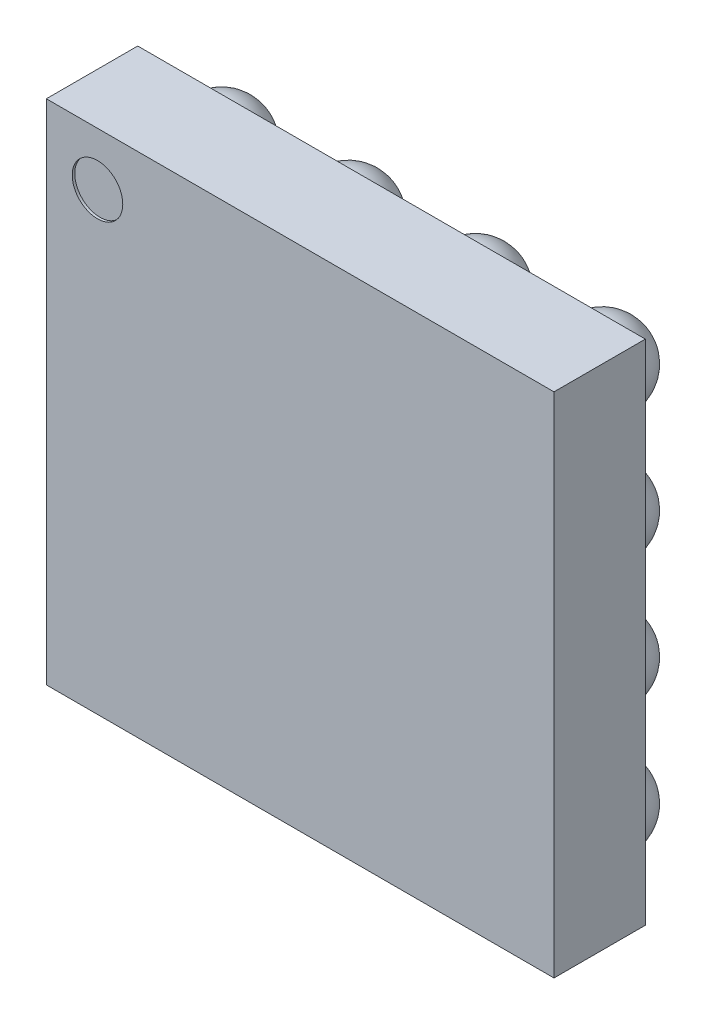
from build123d import *

# Parameters (mm, degrees)
BOSS_EXTRUDE1_START  = 0.24
SKETCH1_W            = 2
SKETCH1_H            = 2
BOSS_EXTRUDE1_DEPTH  = 0.36
LPATTERN1_COUNT      = 4
LPATTERN1_PITCH      = 0.5
LPATTERN1_COUNT_DIR2 = 4
LPATTERN1_PITCH_DIR2 = 0.5
SKETCH3_R            = 0.0995871
CUT_EXTRUDE1_DEPTH   = 0.01


with BuildPart() as part:
    # Sketch1 → Boss-Extrude1 (new body)
    with BuildSketch(Plane.XY.offset(BOSS_EXTRUDE1_START)):
        Rectangle(SKETCH1_W, SKETCH1_H)
    extrude(amount=BOSS_EXTRUDE1_DEPTH)

    # Sketch2 → Revolve1 (revolve)
    with BuildSketch(Plane(origin=(0.75, 0, 0), x_dir=(0, 0, -1), z_dir=(1, 0, 0))):
        with BuildLine():
            Line((-0.32, 0.75), (0, 0.75))
            ThreePointArc((0, 0.75), (-0.16, 0.59), (-0.32, 0.75))
        make_face()
    revolve1 = revolve(axis=Axis((0.75, 0.75, 0.32), (0, 0, -1)))

    # LPattern1: Revolve1 4 × 4
    with Locations(*[(-i * LPATTERN1_PITCH, -j * LPATTERN1_PITCH_DIR2, 0) for i in range(LPATTERN1_COUNT) for j in range(LPATTERN1_COUNT_DIR2) if (i, j) != (0, 0)]):
        add(revolve1)

    # Sketch3 → Cut-Extrude1 (cut)
    with BuildSketch(Plane.XY.offset(0.6)):
        with Locations((-0.798559078, 0.790600018)):
            Circle(SKETCH3_R)
    extrude(amount=-CUT_EXTRUDE1_DEPTH, mode=Mode.SUBTRACT)


solid = part.part
